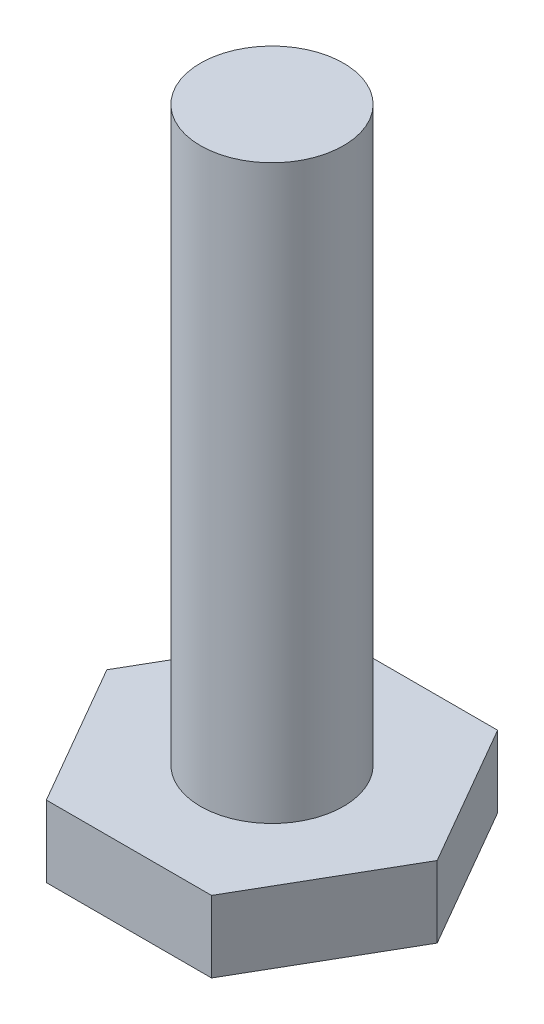
from build123d import *

# Parameters (mm, degrees)
BOSS_EXTRUDE1_DEPTH = 3.175
SKETCH2_R           = 3.175
BOSS_EXTRUDE2_DEPTH = 25.4


with BuildPart() as part:
    # Sketch1 → Boss-Extrude1 (new body)
    with BuildSketch(Plane(origin=(0, 0, 0), x_dir=(1, 0, 0), z_dir=(0, 1, 0))):
        Polygon((3.666174209, 6.35), (-3.666174209, 6.35), (-7.332348419, 0), (-3.666174209, -6.35), (3.666174209, -6.35), (7.332348419, 0), align=None)
    extrude(amount=BOSS_EXTRUDE1_DEPTH)

    # Sketch2 → Boss-Extrude2 (add)
    with BuildSketch(Plane(origin=(0, 3.175, 0), x_dir=(1, 0, 0), z_dir=(0, 1, 0))):
        Circle(SKETCH2_R)
    extrude(amount=BOSS_EXTRUDE2_DEPTH)


solid = part.part
